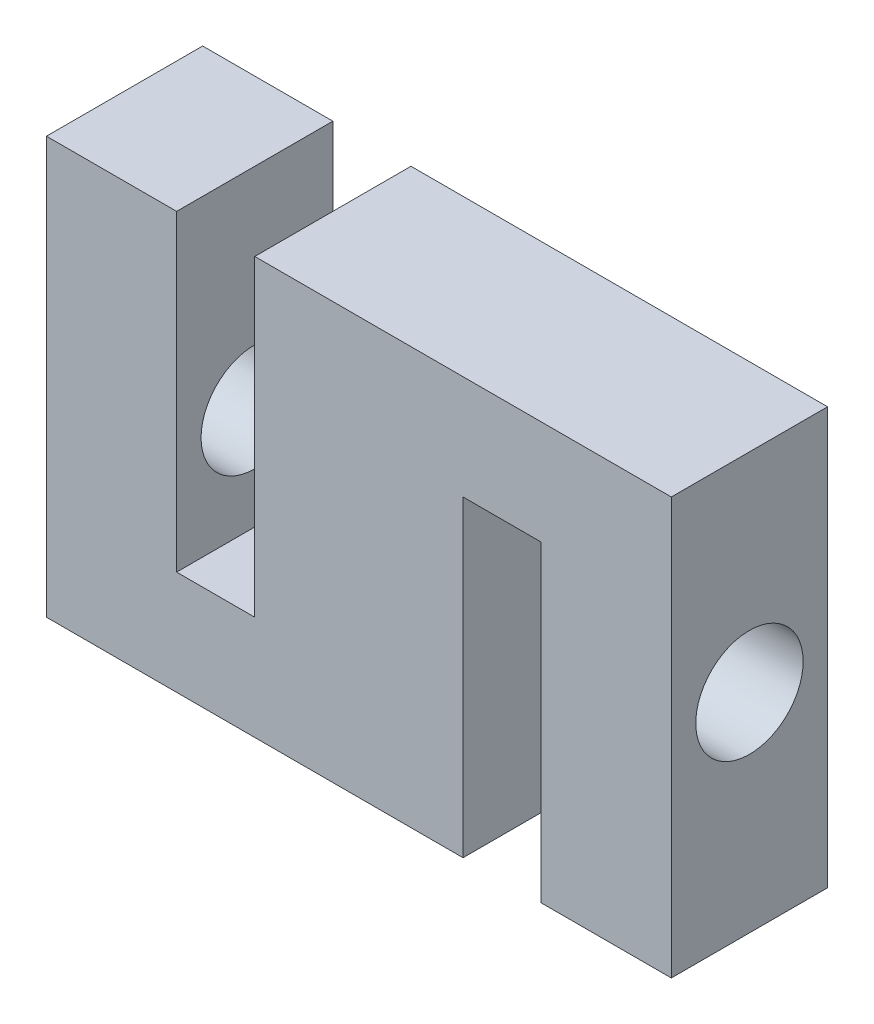
from build123d import *

# Parameters (mm, degrees)
BOSS_EXTRUDE1_DEPTH         = 19.05
F_1_2_CLEARANCE_HOLE1_D     = 13.09624
F_1_2_CLEARANCE_HOLE1_DEPTH = 15.875
F_1_2_CLEARANCE_HOLE2_D     = 13.09624
F_1_2_CLEARANCE_HOLE2_DEPTH = 15.875


with BuildPart() as part:
    # Sketch1 → Boss-Extrude1 (new body)
    with BuildSketch(Plane.XY):
        Polygon((0, 0), (0, 50.8), (15.875, 50.8), (15.875, 12.7), (25.4, 12.7), (25.4, 50.8), (76.2, 50.8), (76.2, 0), (60.325, 0), (60.325, 38.1), (50.8, 38.1), (50.8, 0), align=None)
    extrude(amount=BOSS_EXTRUDE1_DEPTH)

    # 1/2 Clearance Hole1
    with Locations(Plane.ZY):
        with Locations((9.525, 25.4)):
            Hole(F_1_2_CLEARANCE_HOLE1_D / 2, depth=F_1_2_CLEARANCE_HOLE1_DEPTH)

    # 1/2 Clearance Hole2
    with Locations(Plane(origin=(76.2, 0, 0), x_dir=(0, 0, -1), z_dir=(1, 0, 0))):
        with Locations((-9.525, 25.4)):
            Hole(F_1_2_CLEARANCE_HOLE2_D / 2, depth=F_1_2_CLEARANCE_HOLE2_DEPTH)


solid = part.part
